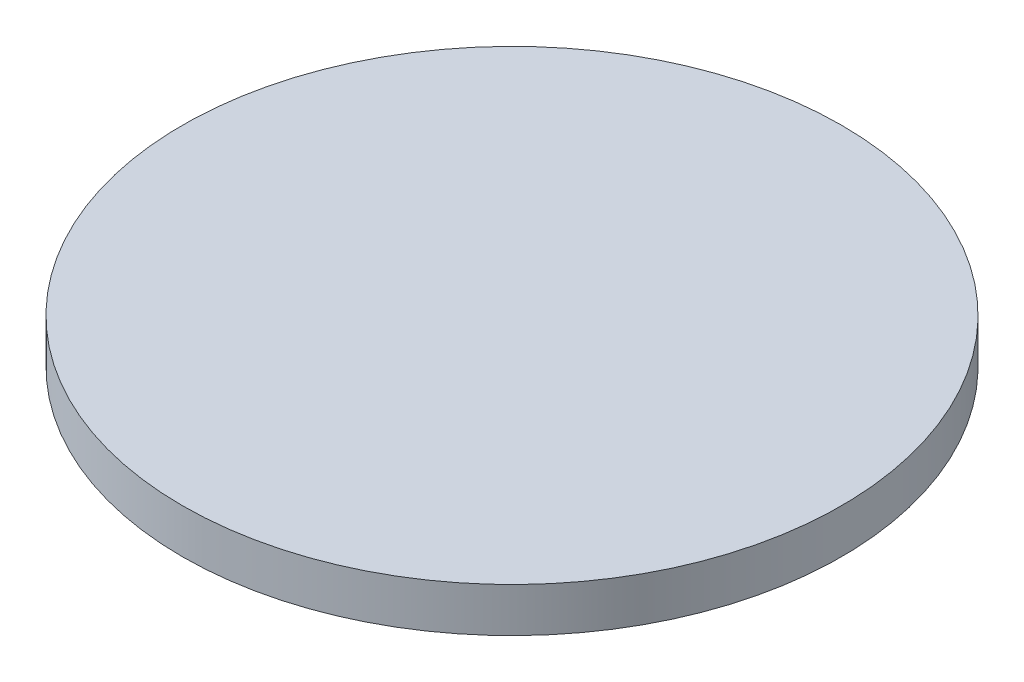
from build123d import *

# Parameters (mm, degrees)
SKETCH1_R           = 35
BOSS_EXTRUDE1_DEPTH = 4.7


with BuildPart() as part:
    # Sketch1 → Boss-Extrude1 (new body)
    with BuildSketch(Plane(origin=(0, 0, 0), x_dir=(1, 0, 0), z_dir=(0, 1, 0))):
        Circle(SKETCH1_R)
    extrude(amount=BOSS_EXTRUDE1_DEPTH)


solid = part.part
